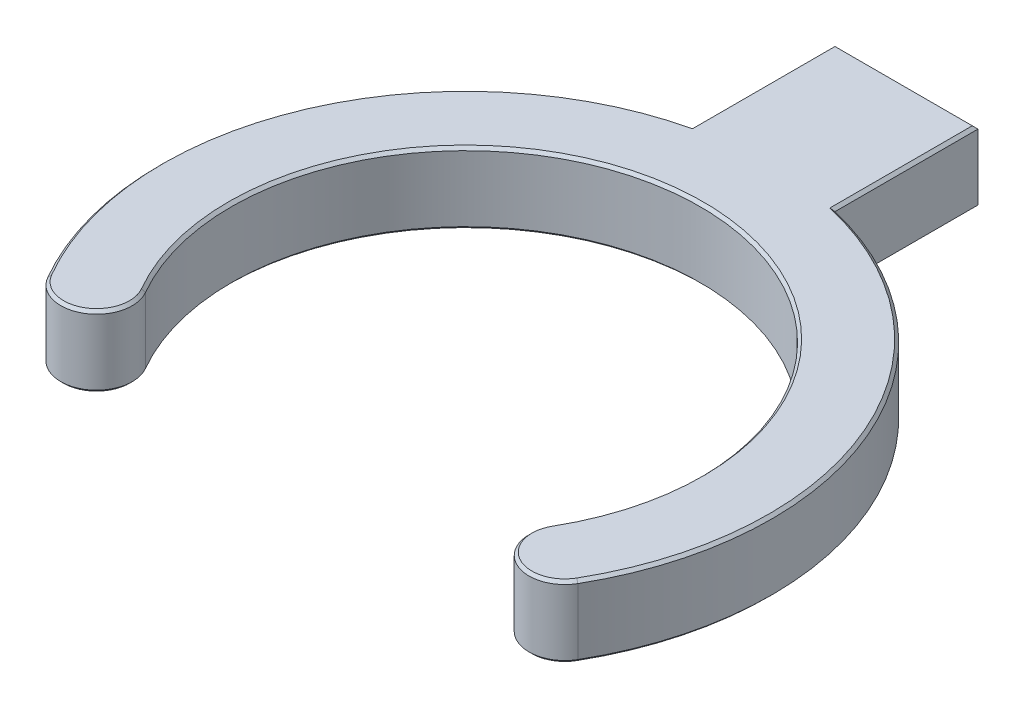
from build123d import *

# Parameters (mm, degrees)
BOSS_EXTRUDE1_DEPTH = 5
CHAMFER1_SIZE       = 0.2


with BuildPart() as part:
    # Sketch1 → Boss-Extrude1 (new body)
    with BuildSketch(Plane(origin=(0, 0, 0), x_dir=(1, 0, 0), z_dir=(0, 1, 0))):
        with BuildLine():
            Line((-5, 30.807690886), (5, 30.807690886))
            Line((5, 30.807690886), (5, 20.807690886))
            ThreePointArc((5, 20.807690886), (19.662998381, 8.445501445), (18.532943641, -10.7))
            ThreePointArc((18.532943641, -10.7), (15.117880132, -11.615063509), (14.202816622, -8.2))
            ThreePointArc((14.202816622, -8.2), (0, 16.4), (-14.202816622, -8.2))
            ThreePointArc((-14.202816622, -8.2), (-15.117880132, -11.615063509), (-18.532943641, -10.7))
            ThreePointArc((-18.532943641, -10.7), (-19.662998381, 8.445501445), (-5, 20.807690886))
            Line((-5, 20.807690886), (-5, 30.807690886))
        make_face()
    extrude(amount=BOSS_EXTRUDE1_DEPTH)

    # Chamfer1
    chamfer1_edges = [part.edges().sort_by_distance(p)[0] for p in [
        (15.117880132, 0, 11.615063509),
        (0, 0, -16.4),
        (-15.117880132, 0, 11.615063509),
        (-19.662998381, 0, -8.445501445),
        (0, 5, -16.4),
        (15.117880132, 5, 11.615063509),
        (19.662998381, 5, -8.445501445),
        (5, 5, -25.807690886),
        (0, 5, -30.807690886),
        (-5, 5, -25.807690886),
        (-19.662998381, 5, -8.445501445),
        (-5, 0, -25.807690886),
        (-15.117880132, 5, 11.615063509),
        (0, 0, -30.807690886),
        (5, 0, -25.807690886),
        (19.662998381, 0, -8.445501445),
    ]]
    chamfer(chamfer1_edges, length=CHAMFER1_SIZE)


solid = part.part
